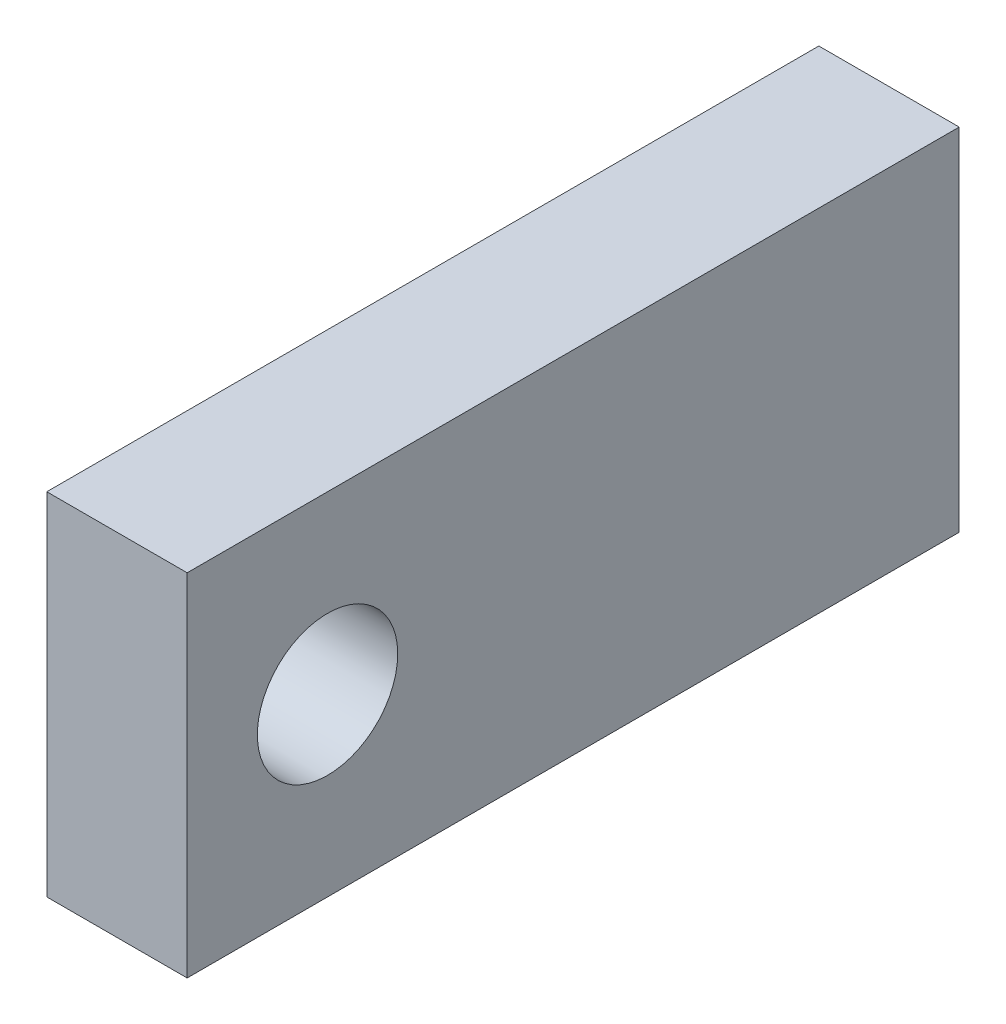
from build123d import *

# Parameters (mm, degrees)
SKETCH1_W           = 12.7
SKETCH1_H           = 31.75
SKETCH1_R           = 3.175
BOSS_EXTRUDE1_DEPTH = 69.85
SKETCH2_R           = 3.175
BOSS_EXTRUDE2_DEPTH = 50.8
SKETCH3_R           = 6.35
CUT_EXTRUDE1_DEPTH  = 13.7


with BuildPart() as part:
    # Sketch1 → Boss-Extrude1 (new body)
    with BuildSketch(Plane.XY):
        Rectangle(SKETCH1_W, SKETCH1_H)
        with Locations((0, 9.525)):
            Circle(SKETCH1_R, mode=Mode.SUBTRACT)
        with Locations((0, -9.525)):
            Circle(SKETCH1_R, mode=Mode.SUBTRACT)
    extrude(amount=BOSS_EXTRUDE1_DEPTH)

    # Sketch2 → Boss-Extrude2 (add)
    with BuildSketch(Plane.XY.offset(69.85)):
        with Locations((0, -9.525)):
            Circle(SKETCH2_R)
        with Locations((0, 9.525)):
            Circle(SKETCH2_R)
    extrude(amount=-BOSS_EXTRUDE2_DEPTH)

    # Sketch3 → Cut-Extrude1 (cut, through all)
    with BuildSketch(Plane(origin=(6.35, 0, 0), x_dir=(0, 0, -1), z_dir=(1, 0, 0))):
        with Locations((-57.15, 0)):
            Circle(SKETCH3_R)
    extrude(amount=-CUT_EXTRUDE1_DEPTH, mode=Mode.SUBTRACT)


solid = part.part
